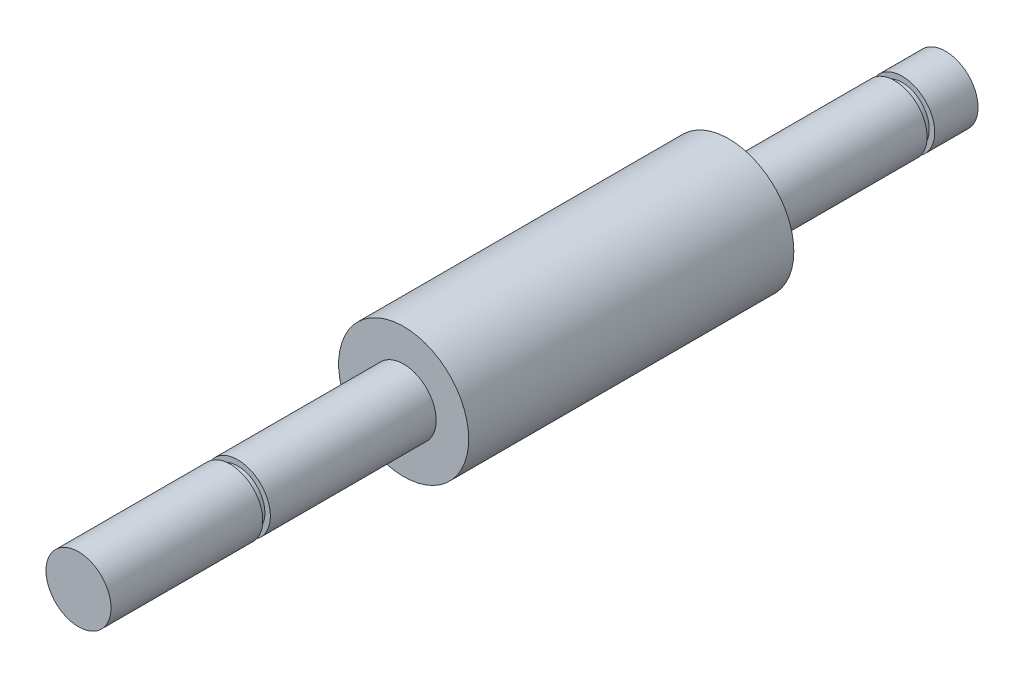
from build123d import *

# Parameters (mm, degrees)
SKETCH_1_R          = 6
EXTRUDE_1_DEPTH     = 30
SKETCH_2_R          = 3
EXTRUDE_2_DEPTH     = 20
SKETCH_3_R          = 3
EXTRUDE_3_DEPTH     = 30
SKETCH_4_R          = 6.707362288
SKETCH_4_R_2        = 2.5
CUT_EXTRUDE_1_DEPTH = 0.7
SKETCH_5_R          = 8.291110755
SKETCH_5_R_2        = 2.5
CUT_EXTRUDE_2_DEPTH = 0.7


with BuildPart() as part:
    # 草图1 → 凸台-拉伸1 (new body)
    with BuildSketch(Plane.XY):
        Circle(SKETCH_1_R)
    extrude(amount=EXTRUDE_1_DEPTH)

    # 草图2 → 凸台-拉伸2 (add)
    with BuildSketch(Plane(origin=(0, 0, 0), x_dir=(-1, 0, 0), z_dir=(0, 0, -1))):
        Circle(SKETCH_2_R)
    extrude(amount=EXTRUDE_2_DEPTH)

    # 草图3 → 凸台-拉伸3 (add)
    with BuildSketch(Plane.XY.offset(30)):
        Circle(SKETCH_3_R)
    extrude(amount=EXTRUDE_3_DEPTH)

    # 草图4 → 切除-拉伸1 (cut)
    with BuildSketch(Plane(origin=(0, 0, -16), x_dir=(-1, 0, 0), z_dir=(0, 0, -1))):
        Circle(SKETCH_4_R)
        Circle(SKETCH_4_R_2, mode=Mode.SUBTRACT)
    extrude(amount=-CUT_EXTRUDE_1_DEPTH, mode=Mode.SUBTRACT)

    # 草图5 → 切除-拉伸2 (cut)
    with BuildSketch(Plane(origin=(0, 0, 45.3), x_dir=(-1, 0, 0), z_dir=(0, 0, -1))):
        Circle(SKETCH_5_R)
        Circle(SKETCH_5_R_2, mode=Mode.SUBTRACT)
    extrude(amount=-CUT_EXTRUDE_2_DEPTH, mode=Mode.SUBTRACT)


solid = part.part
